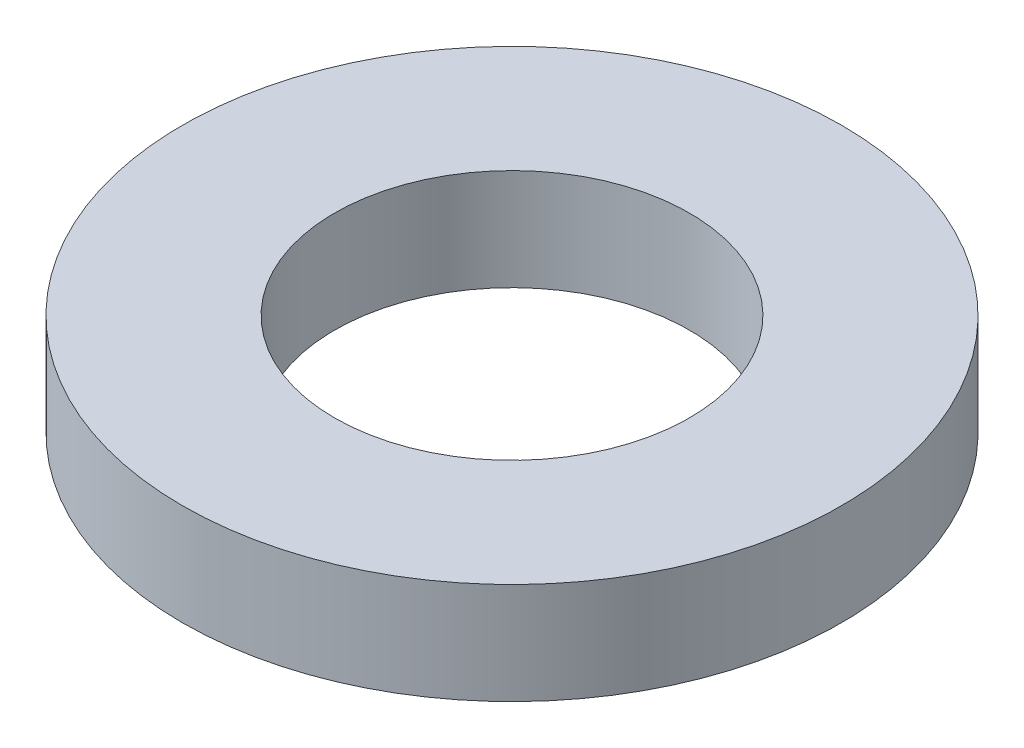
from build123d import *

# Parameters (mm, degrees)
SKIZZE1_R                       = 3.25
SKIZZE1_R_2                     = 1.75
AUFSATZ_LINEAR_AUSTRAGEN1_DEPTH = 1


with BuildPart() as part:
    # Skizze1 → Aufsatz-Linear austragen1 (new body)
    with BuildSketch(Plane(origin=(0, 0, 0), x_dir=(1, 0, 0), z_dir=(0, 1, 0))):
        Circle(SKIZZE1_R)
        Circle(SKIZZE1_R_2, mode=Mode.SUBTRACT)
    extrude(amount=AUFSATZ_LINEAR_AUSTRAGEN1_DEPTH)


solid = part.part
